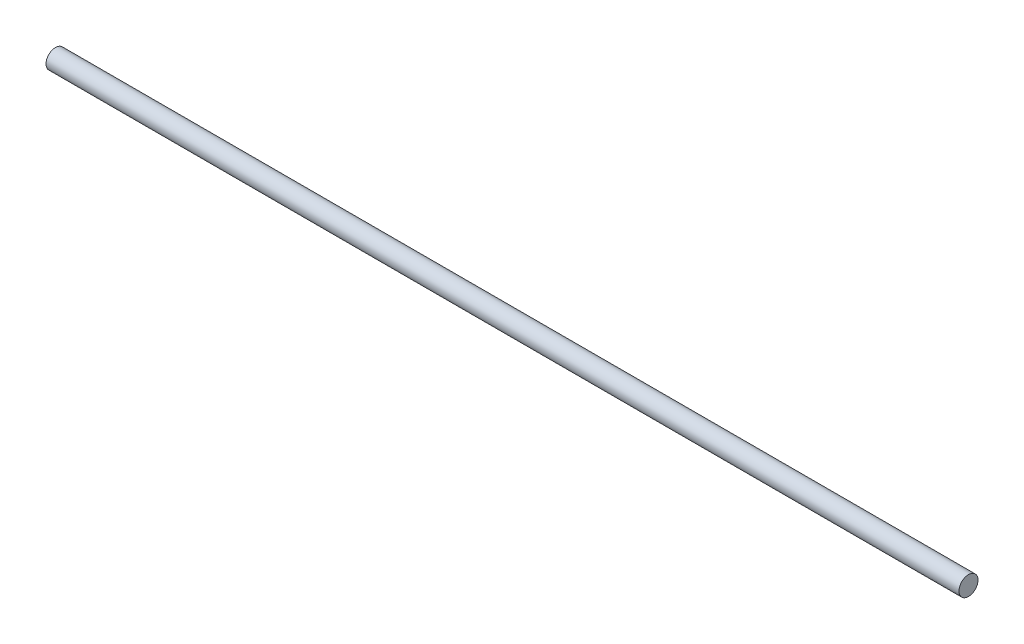
from build123d import *

# Parameters (mm, degrees)
SWEEP1_PROFILE_R = 9.525


with BuildPart() as part:
    # Sweep1: sweep along a path in Sketch1
    with BuildLine(Plane(origin=(0, 0, 0), x_dir=(1, 0, 0), z_dir=(0, 1, 0))) as sweep1_path:
        Line((0, 0), (-914.4, 0))
    # Sweep1 profile (on start of the path) → Sweep1 (sweep)
    with BuildSketch(Plane(origin=(0, 0, 0), x_dir=(0, 0, -1), z_dir=(-1, 0, 0))):
        Circle(SWEEP1_PROFILE_R)
    sweep(path=sweep1_path.line)


solid = part.part
